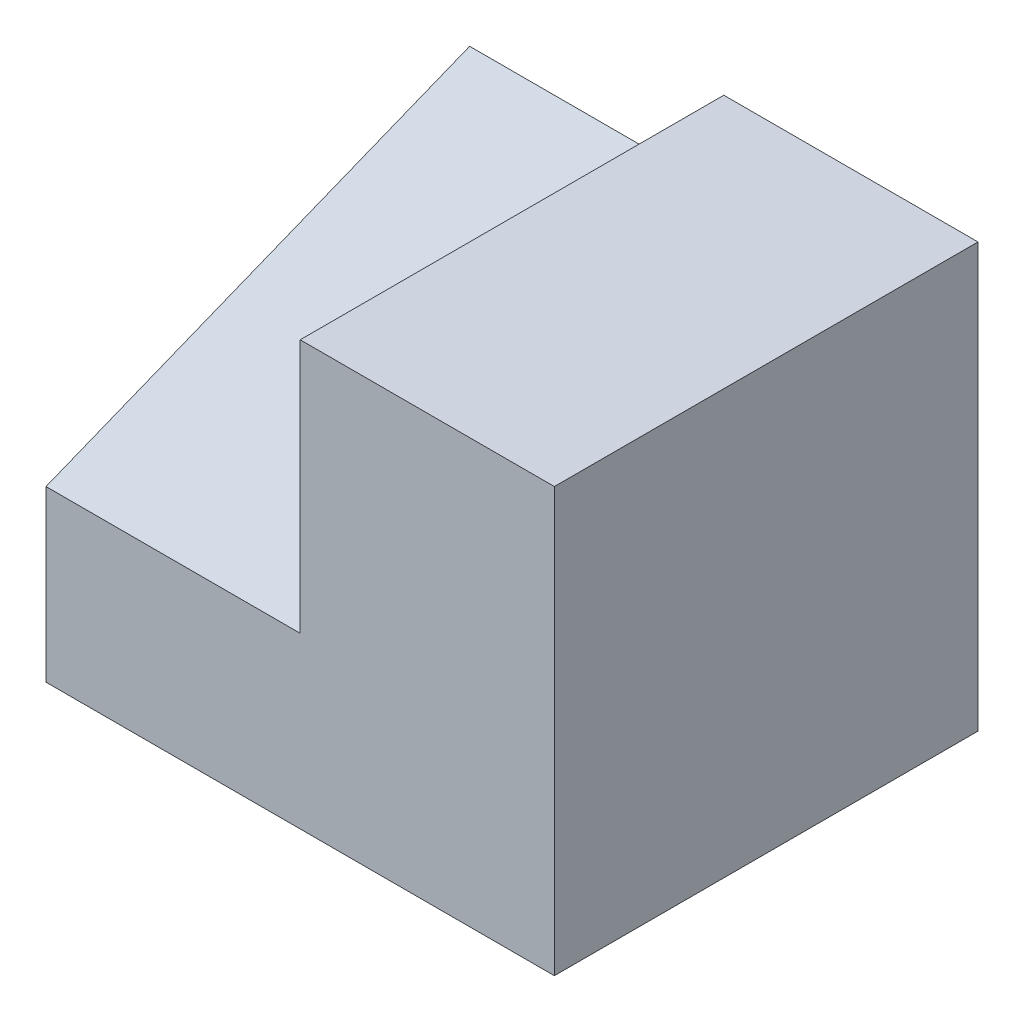
from build123d import *

# Parameters (mm, degrees)
BOSS_EXTRUDE1_DEPTH = 25
BOSS_EXTRUDE4_DEPTH = 15


with BuildPart() as part:
    # Sketch1 → Boss-Extrude1 (new body)
    with BuildSketch(Plane.XY):
        Polygon((-15, 25), (0, 25), (0, 0), (-30, 0), (-30, 10), (-15, 10), align=None)
    extrude(amount=BOSS_EXTRUDE1_DEPTH)

    # Sketch5 → Boss-Extrude4 (add)
    with BuildSketch(Plane.ZY.offset(15)):
        Polygon((0, 10), (0, 20), (25, 10), align=None)
    extrude(amount=BOSS_EXTRUDE4_DEPTH)


solid = part.part
